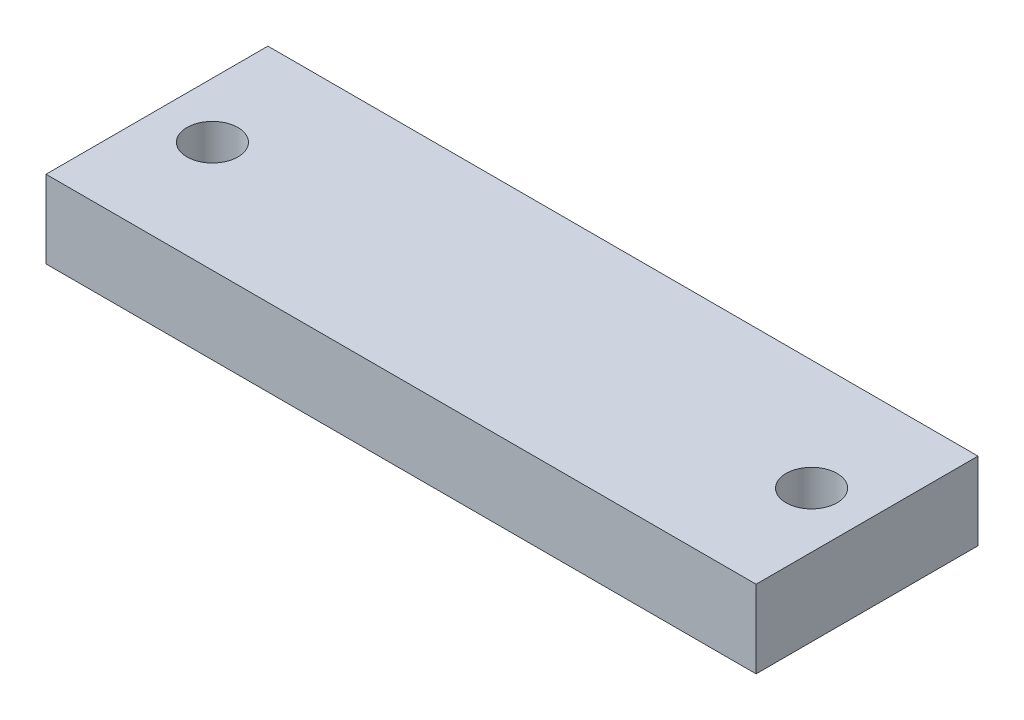
from build123d import *

# Parameters (mm, degrees)
SKETCH1_W           = 64
SKETCH1_H           = 20
SKETCH1_R           = 2.3
BOSS_EXTRUDE1_DEPTH = 7


with BuildPart() as part:
    # Sketch1 → Boss-Extrude1 (new body)
    with BuildSketch(Plane(origin=(0, 0, 0), x_dir=(1, 0, 0), z_dir=(0, 1, 0))):
        with Locations((32, 10)):
            Rectangle(SKETCH1_W, SKETCH1_H)
        with Locations((59, 10)):
            Circle(SKETCH1_R, mode=Mode.SUBTRACT)
        with Locations((5, 10)):
            Circle(SKETCH1_R, mode=Mode.SUBTRACT)
    extrude(amount=BOSS_EXTRUDE1_DEPTH)


solid = part.part
